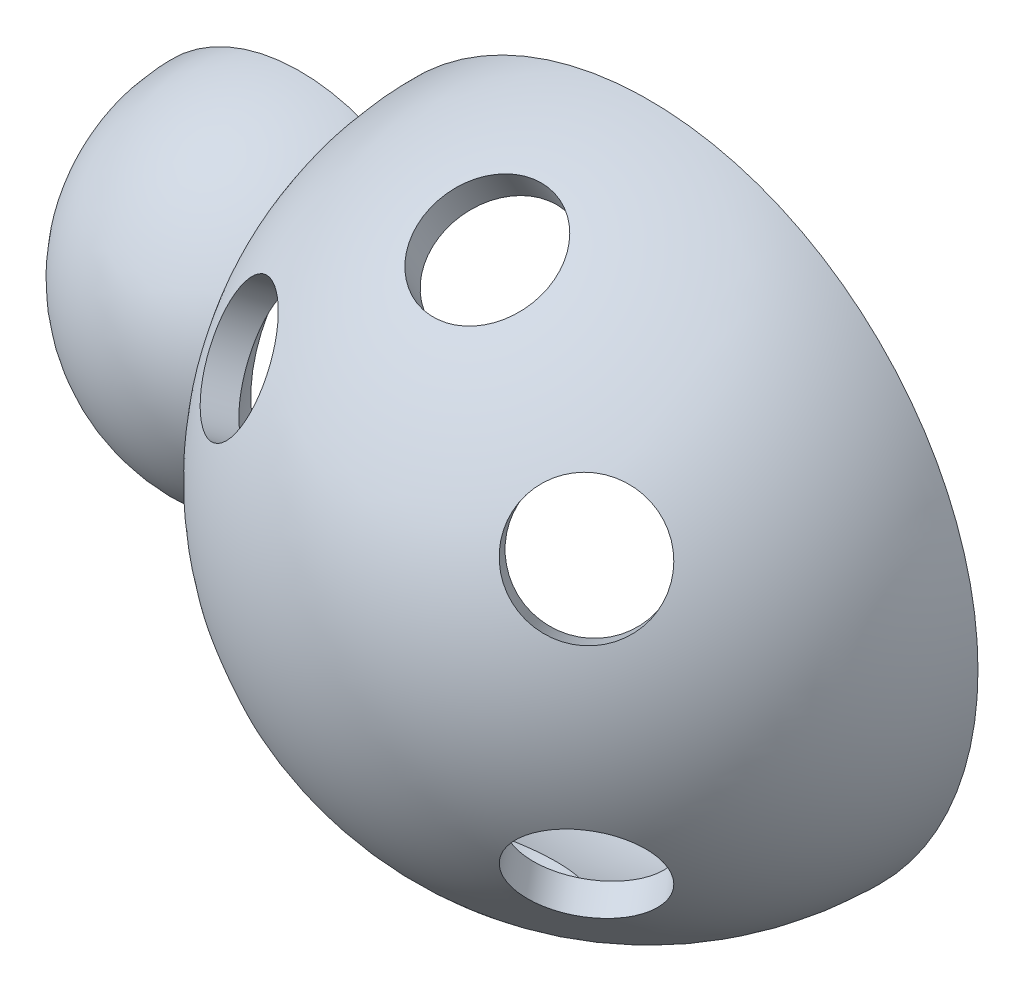
from build123d import *

# Parameters (mm, degrees)
REVOLVE1_ANGLE     = 180
SKETCH3_R          = 12.5
SPOT1_DEPTH        = 10
SKETCH4_R          = 12.5
SPOT2_DEPTH        = 10
SKETCH6_R          = 12.5
SPOT3_DEPTH        = 10
SKETCH7_W          = 8.5
SKETCH7_H          = 12.7
CUT_EXTRUDE4_DEPTH = 107


with BuildPart() as part:
    # Sketch1 → Revolve1 (revolve)
    with BuildSketch(Plane.XY):
        with BuildLine():
            Line((-106, 0), (-100, 0))
            ThreePointArc((-100, 0), (-84.638501094, 26.186146828), (-54.285714286, 25.5550626))
            ThreePointArc((-54.285714286, 25.5550626), (13.093073414, 58.554004377), (60, 0))
            Line((60, 0), (66, 0))
            ThreePointArc((66, 0), (17.369924747, 63.673273155), (-56.857142857, 33.515150397))
            ThreePointArc((-56.857142857, 33.515150397), (-90.283702113, 29.741745554), (-106, 0))
        make_face()
    revolve(axis=Axis((-106, 0, 0), (1, 0, 0)), revolution_arc=REVOLVE1_ANGLE)

    # Sketch3 → Spot1 (cut)
    with BuildSketch(Plane(origin=(-35.461774151, 27.831917712, 48.206295549), x_dir=(0.833827643, 0.395653782, 0.384953954), z_dir=(-0.537299608, 0.421695723, 0.730398417))):
        Circle(SKETCH3_R)
    spot1 = extrude(amount=-SPOT1_DEPTH, mode=Mode.SUBTRACT)

    # Sketch4 → Spot2 (cut)
    with BuildSketch(Plane(origin=(35.461774151, 27.831917712, 48.206295549), x_dir=(0.843391446, -0.268649804, -0.46531511), z_dir=(0.537299608, 0.421695723, 0.730398417))):
        Circle(SKETCH4_R)
    spot2 = extrude(amount=-SPOT2_DEPTH, mode=Mode.SUBTRACT)

    # Sketch6 → Spot3 (cut)
    with BuildSketch(Plane(origin=(0, 57.15767665, 33), x_dir=(1, 0, 0), z_dir=(0, 0.866025404, 0.5))):
        Circle(SKETCH6_R)
    spot3 = extrude(amount=-SPOT3_DEPTH, mode=Mode.SUBTRACT)

    # Mirror1: Spot1, Spot2, Spot3 across plane
    add(spot1.mirror(Plane.ZX), mode=Mode.SUBTRACT)
    add(spot2.mirror(Plane.ZX), mode=Mode.SUBTRACT)
    add(spot3.mirror(Plane.ZX), mode=Mode.SUBTRACT)

    # Sketch7 → Cut-Extrude4 (cut, through all)
    with BuildSketch(Plane(origin=(0, 0, 0), x_dir=(0, 0, -1), z_dir=(1, 0, 0))):
        with Locations((-4.25, 0)):
            Rectangle(SKETCH7_W, SKETCH7_H)
    extrude(amount=-CUT_EXTRUDE4_DEPTH, mode=Mode.SUBTRACT)


solid = part.part
